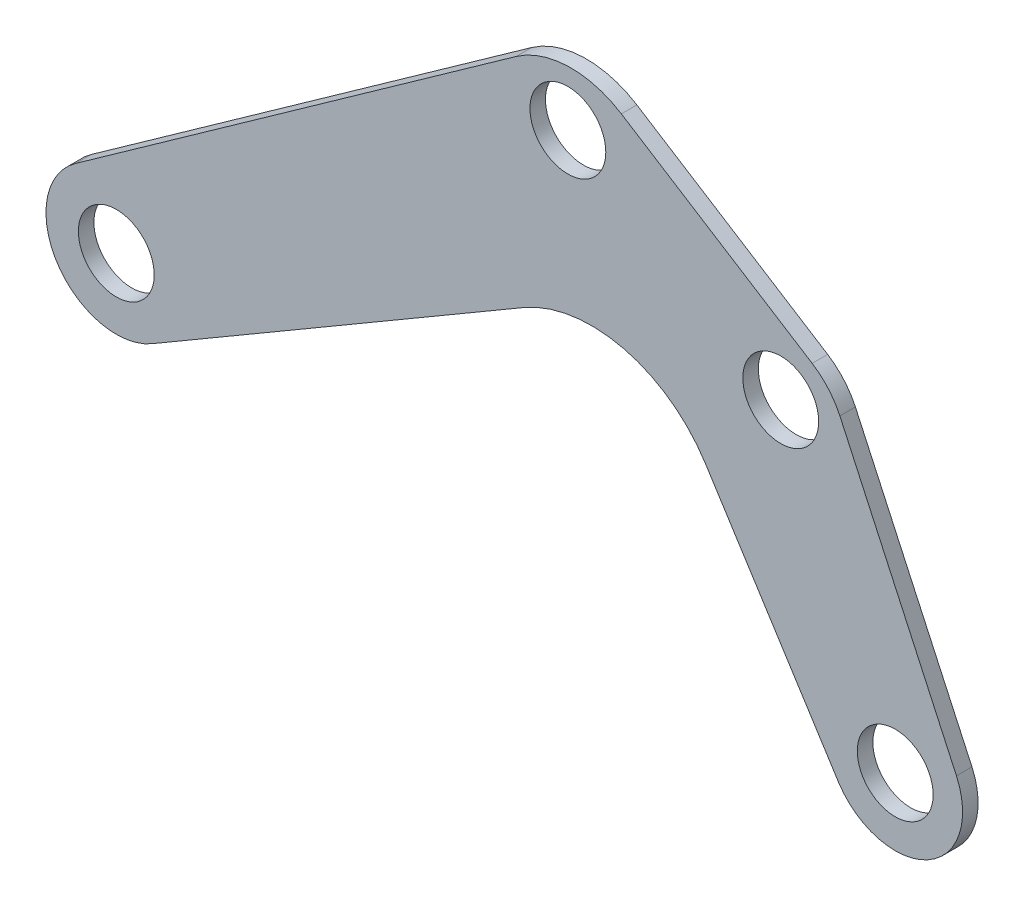
from build123d import *

# Parameters (mm, degrees)
SKETCH1_R           = 14.2875
BOSS_EXTRUDE1_DEPTH = 5.842
FILLET6_R           = 35.56
FILLET10_R          = 27.94
FILLET13_R          = 50.8


with BuildPart() as part:
    # Sketch1 → Boss-Extrude1 (new body)
    with BuildSketch(Plane(origin=(0, 0, 0), x_dir=(-1, 0, 0), z_dir=(0, 0, -1))):
        with BuildLine():
            Line((316.43857867, 42.94910124), (130.990896358, 174.671247093))
            Line((130.990896358, 174.671247093), (31.981087973, 112.057039535))
            Line((31.981087973, 112.057039535), (-15.378230565, 9.100654441))
            ThreePointArc((-15.378230565, 9.100654441), (-4.576133352, -23.72569398), (28.948253716, -15.337015504))
            Line((28.948253716, -15.337015504), (105.434059084, 104.999617888))
            Line((105.434059084, 104.999617888), (287.729052218, -1.503728312))
            ThreePointArc((287.729052218, -1.503728312), (323.338289689, 6.995643737), (316.43857867, 42.94910124))
        make_face()
        with Locations((301.089652101, 21.3647594)):
            Circle(SKETCH1_R, mode=Mode.SUBTRACT)
        with Locations((130.990896358, 146.510317071)):
            Circle(SKETCH1_R, mode=Mode.SUBTRACT)
        with Locations((50.8, 98.679)):
            Circle(SKETCH1_R, mode=Mode.SUBTRACT)
        with Locations((7.675076536, -1.503728312)):
            Circle(SKETCH1_R, mode=Mode.SUBTRACT)
    extrude(amount=-BOSS_EXTRUDE1_DEPTH)

    # Fillet6
    fillet6_edges = [part.edges().sort_by_distance(p)[0] for p in [
        (-130.990896358, 174.671247093, 2.921),
    ]]
    fillet(fillet6_edges, radius=FILLET6_R)

    # Fillet10
    fillet10_edges = [part.edges().sort_by_distance(p)[0] for p in [
        (-31.981087973, 112.057039535, 2.921),
    ]]
    fillet(fillet10_edges, radius=FILLET10_R)

    # Fillet13
    fillet13_edges = [part.edges().sort_by_distance(p)[0] for p in [
        (-105.434059084, 104.999617888, 2.921),
    ]]
    fillet(fillet13_edges, radius=FILLET13_R)


solid = part.part
